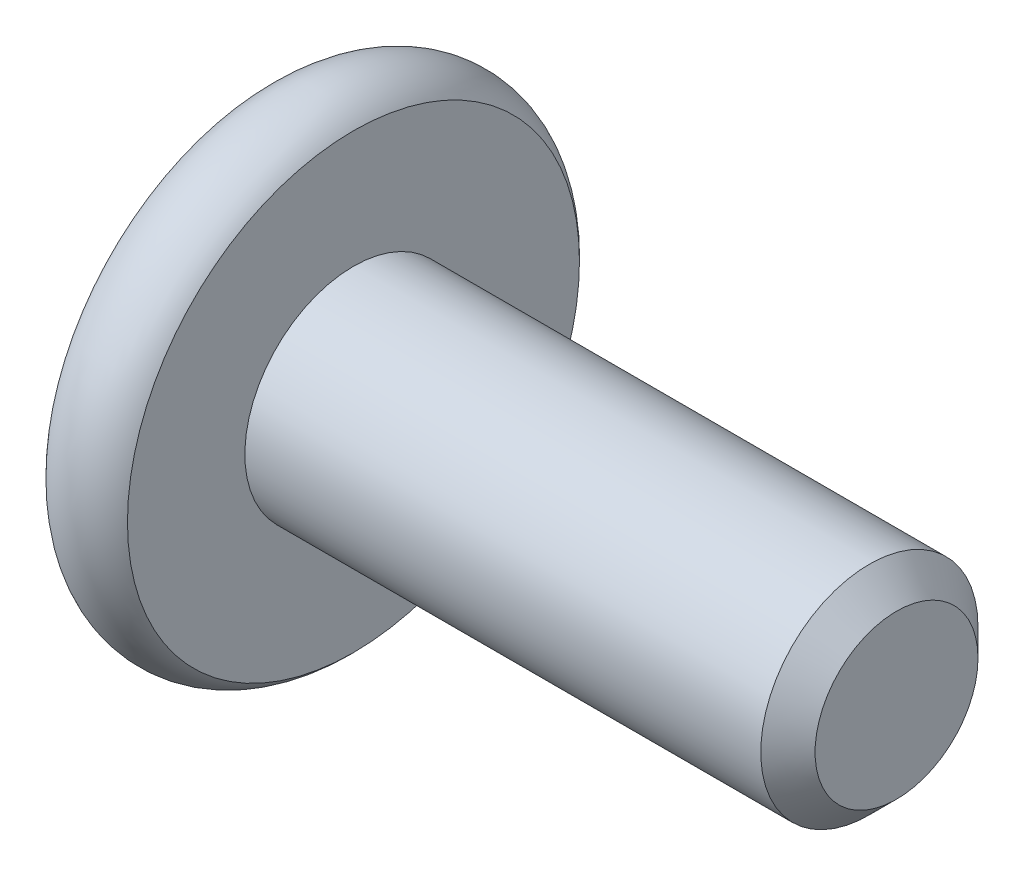
from build123d import *

# Parameters (mm, degrees)
SKETCH2_R           = 2
BOSS_EXTRUDE1_DEPTH = 10
CHAMFER1_SIZE       = 0.5
CUT_EXTRUDE1_DEPTH  = 2.3
SKETCH8_R           = 1.782050808
CUT_EXTRUDE2_DEPTH  = 1
CUT_EXTRUDE2_TAPER  = 45


with BuildPart() as part:
    # Sketch2 → Boss-Extrude1 (new body)
    with BuildSketch(Plane(origin=(0, 0, 0), x_dir=(0, 0, -1), z_dir=(1, 0, 0))):
        Circle(SKETCH2_R)
    extrude(amount=-BOSS_EXTRUDE1_DEPTH)

    # Chamfer1
    chamfer1_edges = [part.edges().sort_by_distance(p)[0] for p in [
        (0, 0, 2),
    ]]
    chamfer(chamfer1_edges, length=CHAMFER1_SIZE)

    # Sketch6 → Revolve1 (revolve)
    with BuildSketch(Plane.XY):
        with BuildLine():
            Line((-11.5, 0), (-11.5, 4.161437828))
            ThreePointArc((-11.5, 4.161437828), (-10.75, 4.5), (-10, 4.161437828))
            Line((-10, 4.161437828), (-10, 0))
            Line((-10, 0), (-11.5, 0))
        make_face()
    revolve(axis=Axis((-10, 0, 0), (-1, 0, 0)))

    # Sketch7 → Cut-Extrude1 (cut)
    with BuildSketch(Plane.ZY.offset(11.5)):
        Polygon((0, 1.732050808), (-1.5, 0.866025404), (-1.5, -0.866025404), (0, -1.732050808), (1.5, -0.866025404), (1.5, 0.866025404), align=None)
    extrude(amount=-CUT_EXTRUDE1_DEPTH, mode=Mode.SUBTRACT)

    # Sketch8 → Cut-Extrude2 (cut)
    with BuildSketch(Plane.ZY.offset(11.5)):
        Circle(SKETCH8_R)
    extrude(amount=-CUT_EXTRUDE2_DEPTH, taper=CUT_EXTRUDE2_TAPER, mode=Mode.SUBTRACT)


solid = part.part
